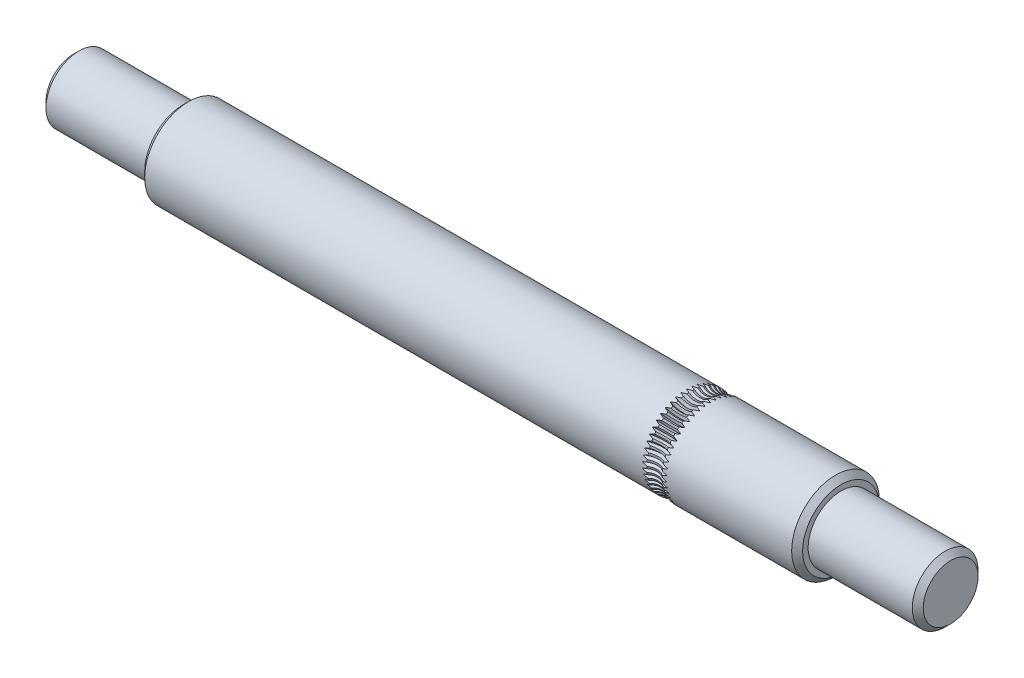
from build123d import *

# Parameters (mm, degrees)
CHAMFER1_SIZE     = 0.5
CIRPATTERN1_COUNT = 50


with BuildPart() as part:
    # Sketch1 → Revolve1 (revolve)
    with BuildSketch(Plane.XY):
        Polygon((-47, 4), (13, 4), (13, 3), (23, 3), (23, 0), (-57, 0), (-57, 3), (-47, 3), align=None)
    revolve(axis=Axis((0, 0, 0), (1, 0, 0)))

    # Chamfer1
    chamfer1_edges = [part.edges().sort_by_distance(p)[0] for p in [
        (-57, -3, 0),
        (23, -3, 0),
        (13, -4, 0),
        (-47, -4, 0),
    ]]
    chamfer(chamfer1_edges, length=CHAMFER1_SIZE)

    # Sketch2 → Cut-Revolve1 (revolve, cut)
    with BuildSketch(Plane(origin=(0, 0, 0), x_dir=(0, 0, -1), z_dir=(1, 0, 0))):
        Polygon((0.156173248, 3.7705), (0, 3.5), (-0.156173248, 3.7705), (-1.3354137, 3.7705), (-1.3354137, 5), (1.3354137, 5), (1.3354137, 3.7705), align=None)
    cut_revolve1 = revolve(axis=Axis((0, 5, -9.989903303), (0, 0, 1)), mode=Mode.SUBTRACT)

    # CirPattern1: Cut-Revolve1 ×50 about axis
    cirpattern1_axis = Axis((0, 0, 0), (-1, 0, 0))
    for i in range(1, CIRPATTERN1_COUNT):
        add(cut_revolve1.rotate(cirpattern1_axis, i * 360 / CIRPATTERN1_COUNT), mode=Mode.SUBTRACT)


solid = part.part
